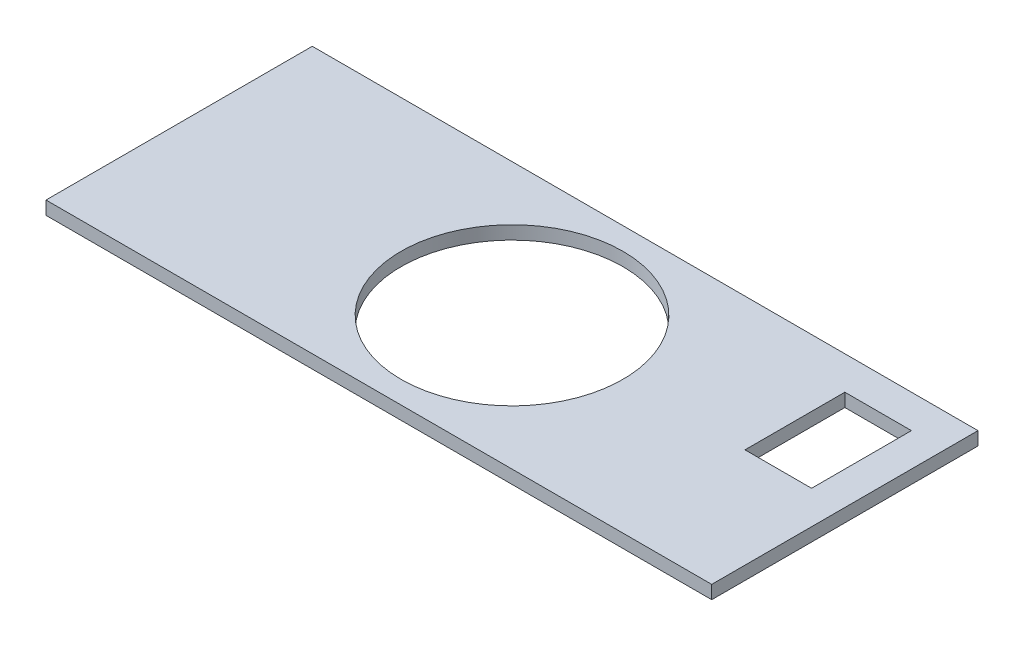
from build123d import *

# Parameters (mm, degrees)
SKETCH1_W           = 300
SKETCH1_H           = 120
SKETCH1_R           = 50
SKETCH1_W_2         = 30
SKETCH1_H_2         = 45
BOSS_EXTRUDE1_DEPTH = 6


with BuildPart() as part:
    # Sketch1 → Boss-Extrude1 (new body)
    with BuildSketch(Plane(origin=(0, 0, 0), x_dir=(1, 0, 0), z_dir=(0, 1, 0))):
        with Locations((150, 60)):
            Rectangle(SKETCH1_W, SKETCH1_H)
        with Locations((150, 60)):
            Circle(SKETCH1_R, mode=Mode.SUBTRACT)
        with Locations((270, 82.5)):
            Rectangle(SKETCH1_W_2, SKETCH1_H_2, mode=Mode.SUBTRACT)
    extrude(amount=BOSS_EXTRUDE1_DEPTH)


solid = part.part
